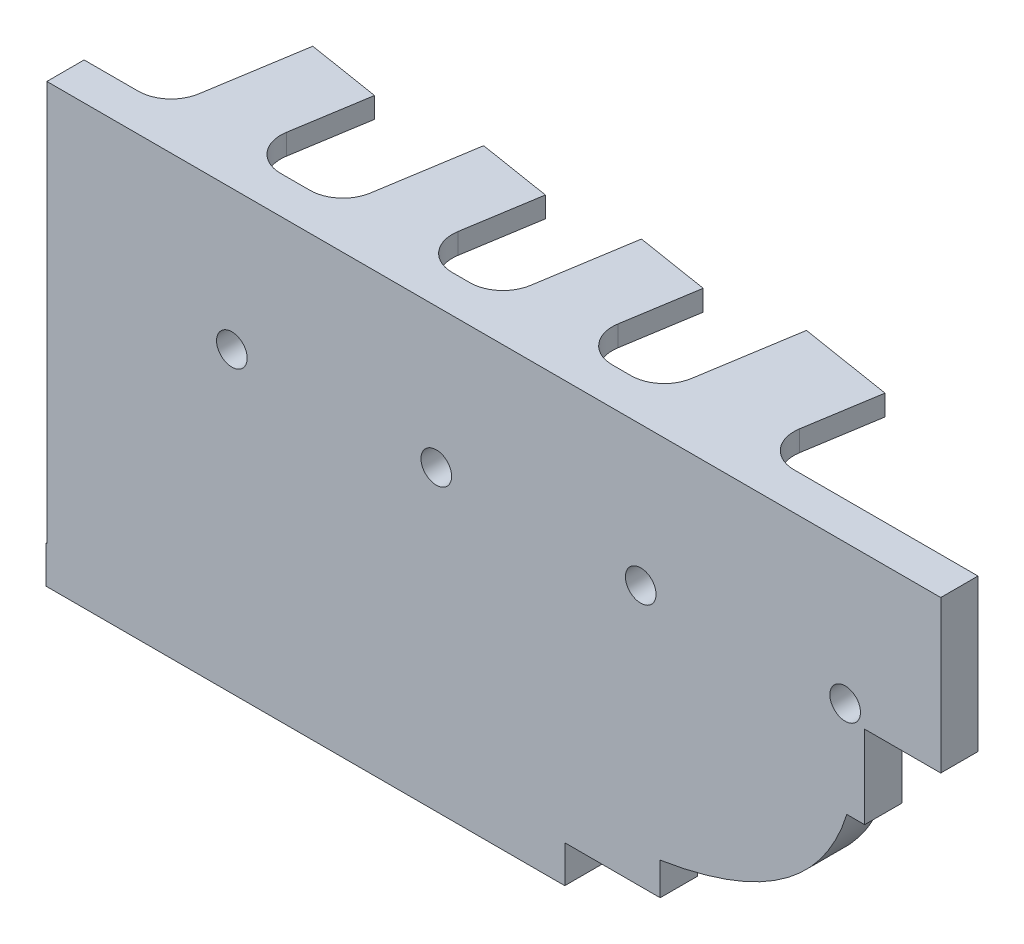
from build123d import *

# Parameters (mm, degrees)
SKETCH1_W           = 24.7
SKETCH1_H           = 21
SKETCH1_R           = 1.05
SKETCH1_R_2         = 1.85000003
SKETCH1_R_3         = 1.050000015
BOSS_EXTRUDE1_DEPTH = 2
LPATTERN1_COUNT     = 4
LPATTERN1_PITCH     = 24.7
SKETCH3_W           = 98.8
SKETCH3_H           = 21
SKETCH3_R           = 1.85000003
BOSS_EXTRUDE2_DEPTH = 2.5
SKETCH4_W           = 98.8
SKETCH4_H           = 4.5
BOSS_EXTRUDE3_DEPTH = 7.36771
SKETCH6_W           = 4.5
SKETCH6_H           = 18.36771
BOSS_EXTRUDE4_DEPTH = 9.198019
SKETCH7_W           = 74.1
SKETCH7_H           = 4.5
BOSS_EXTRUDE5_DEPTH = 20
SKETCH8_W           = 53.178454151
SKETCH8_H           = 4.5
BOSS_EXTRUDE6_DEPTH = 4.5
BOSS_EXTRUDE7_DEPTH = 4.75
BOSS_EXTRUDE8_DEPTH = 2.5
SKETCH14_W          = 4.5
SKETCH14_H          = 4.5
BOSS_EXTRUDE9_DEPTH = 9.5
FILLET1_R           = 4


with BuildPart() as part:
    # Sketch1 → Boss-Extrude1 (new body)
    with BuildSketch(Plane.XY):
        with Locations((12.35, 10.5)):
            Rectangle(SKETCH1_W, SKETCH1_H)
        with Locations((22.850000164, 18.500000119)):
            Circle(SKETCH1_R, mode=Mode.SUBTRACT)
        with Locations((22.850000164, 15.500000119)):
            Circle(SKETCH1_R, mode=Mode.SUBTRACT)
        with Locations((22.350000149, 11.500000015)):
            Circle(SKETCH1_R_2, mode=Mode.SUBTRACT)
        with Locations((20.350000119, 8.49999997)):
            Circle(SKETCH1_R_3, mode=Mode.SUBTRACT)
        with Locations((20.350000119, 6.166666637)):
            Circle(SKETCH1_R_3, mode=Mode.SUBTRACT)
        with Locations((20.350000119, 3.833333304)):
            Circle(SKETCH1_R_3, mode=Mode.SUBTRACT)
        with Locations((20.350000119, 1.49999997)):
            Circle(SKETCH1_R_3, mode=Mode.SUBTRACT)
        with Locations((4.349999881, 8.49999997)):
            Circle(SKETCH1_R_3, mode=Mode.SUBTRACT)
        with Locations((4.349999881, 6.166666637)):
            Circle(SKETCH1_R_3, mode=Mode.SUBTRACT)
        with Locations((4.349999881, 3.833333304)):
            Circle(SKETCH1_R_3, mode=Mode.SUBTRACT)
        with Locations((4.349999881, 1.49999997)):
            Circle(SKETCH1_R_3, mode=Mode.SUBTRACT)
    boss_extrude1 = extrude(amount=BOSS_EXTRUDE1_DEPTH)

    # LPattern1: Boss-Extrude1 ×4
    with Locations(*[(-i * LPATTERN1_PITCH, 0, 0) for i in range(1, LPATTERN1_COUNT)]):
        add(boss_extrude1)

    # Sketch3 → Boss-Extrude2 (add)
    with BuildSketch(Plane.XY.offset(2)):
        with Locations((-24.7, 10.5)):
            Rectangle(SKETCH3_W, SKETCH3_H)
        with Locations((-51.749999851, 11.500000015)):
            Circle(SKETCH3_R, mode=Mode.SUBTRACT)
        with Locations((-27.049999851, 11.500000015)):
            Circle(SKETCH3_R, mode=Mode.SUBTRACT)
        with Locations((-2.349999851, 11.500000015)):
            Circle(SKETCH3_R, mode=Mode.SUBTRACT)
        with Locations((22.350000149, 11.500000015)):
            Circle(SKETCH3_R, mode=Mode.SUBTRACT)
    extrude(amount=BOSS_EXTRUDE2_DEPTH)

    # Sketch4 → Boss-Extrude3 (add)
    with BuildSketch(Plane(origin=(0, 21, 0), x_dir=(1, 0, 0), z_dir=(0, 1, 0))):
        with Locations((-24.7, -2.25)):
            Rectangle(SKETCH4_W, SKETCH4_H)
    extrude(amount=BOSS_EXTRUDE3_DEPTH)

    # Sketch6 → Boss-Extrude4 (add)
    with BuildSketch(Plane(origin=(24.7, 0, 0), x_dir=(0, 0, -1), z_dir=(1, 0, 0))):
        with Locations((-2.25, 19.183855)):
            Rectangle(SKETCH6_W, SKETCH6_H)
    extrude(amount=BOSS_EXTRUDE4_DEPTH)

    # Sketch7 → Boss-Extrude5 (add)
    with BuildSketch(Plane.XZ):
        with Locations((-37.05, 2.25)):
            Rectangle(SKETCH7_W, SKETCH7_H)
    extrude(amount=BOSS_EXTRUDE5_DEPTH)

    # Sketch8 → Boss-Extrude6 (add)
    with BuildSketch(Plane.XZ.offset(20)):
        with Locations((-38.117142498, 2.25)):
            Rectangle(SKETCH8_W, SKETCH8_H)
    extrude(amount=BOSS_EXTRUDE6_DEPTH)

    # Sketch9 → Boss-Extrude7 (add)
    with BuildSketch(Plane.XY.offset(4.5)):
        with BuildLine():
            Line((0, 0), (0, -16.059466978))
            add(Edge.make_bspline(
                [(0, -16.059466978), (18.484574141, -13.097711422), (22.548154032, 0)],
                knots=[0, 0, 0, 0.956663175, 0.956663175, 0.956663175], degree=2))
            Line((22.548154032, 0), (0, 0))
        make_face()
    extrude(amount=-BOSS_EXTRUDE7_DEPTH)

    # Sketch10 → Boss-Extrude8 (add)
    with BuildSketch(Plane(origin=(0, 28.36771, 0), x_dir=(1, 0, 0), z_dir=(0, 1, 0))):
        Polygon((-64.88730383, -4.5), (-61.722013793, 15.247935056), (-52.835443017, 13.823554539), (-55.051146044, 0), (-43.421268353, 0), (-40.991049642, 15.161896923), (-32.104478867, 13.737516406), (-34.306391305, 0), (-24.086432643, 0), (-21.693532902, 14.929067518), (-12.806962127, 13.504687001), (-15.036483854, -0.405081066), (-4.619230317, 0), (-2.161338866, 15.334544441), (9.14228964, 13.522746772), (6.974801469, 0), (6.974801469, -4.5), align=None)
    extrude(amount=-BOSS_EXTRUDE8_DEPTH)

    # Sketch14 → Boss-Extrude9 (add)
    with BuildSketch(Plane.ZY.offset(64.706369573)):
        with Locations((2.25, -22.25)):
            Rectangle(SKETCH14_W, SKETCH14_H)
    extrude(amount=BOSS_EXTRUDE9_DEPTH)

    # Fillet1
    fillet1_edges = [part.edges().sort_by_distance(p)[0] for p in [
        (6.974801469, 27.11771, 0),
        (-4.619230317, 27.11771, 0),
        (-14.971555594, 27.11771, 0),
        (-24.086432643, 27.11771, 0),
        (-34.306391305, 27.11771, 0),
        (-43.421268353, 27.11771, 0),
        (-55.051146044, 27.11771, 0),
        (-64.166023092, 27.11771, 0),
    ]]
    fillet(fillet1_edges, radius=FILLET1_R)


solid = part.part
